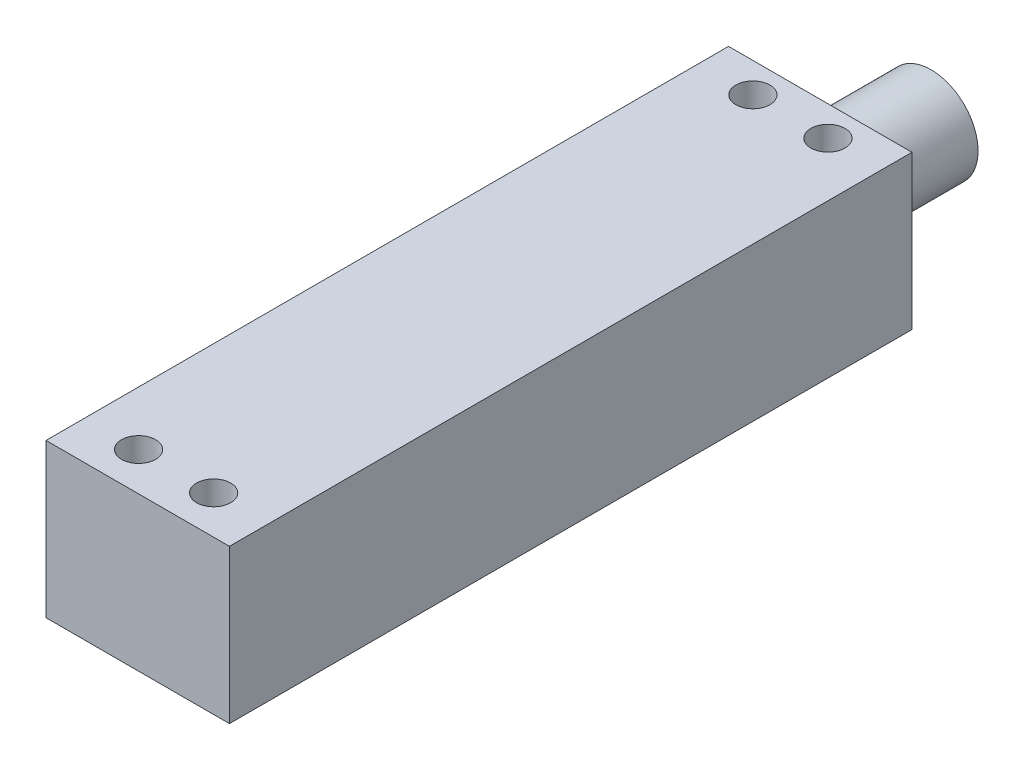
from build123d import *

# Parameters (mm, degrees)
BOSS_EXTRUDE6_START = 10
SKETCH22_W          = 21.5
SKETCH22_H          = 80
BOSS_EXTRUDE6_DEPTH = 18
SKETCH23_R          = 2
CUT_EXTRUDE9_DEPTH  = 4
SKETCH24_R          = 5.5
SKETCH24_R_2        = 4
BOSS_EXTRUDE7_DEPTH = 13


with BuildPart() as part:
    # Sketch22 → Boss-Extrude6 (new body)
    with BuildSketch(Plane(origin=(0, 0, 0), x_dir=(1, 0, 0), z_dir=(0, 1, 0)).offset(BOSS_EXTRUDE6_START)):
        with Locations((-5.25, -159.399454256)):
            Rectangle(SKETCH22_W, SKETCH22_H)
    extrude(amount=BOSS_EXTRUDE6_DEPTH)

    # Sketch23 → Cut-Extrude9 (cut)
    with BuildSketch(Plane(origin=(0, 28, 0), x_dir=(1, 0, 0), z_dir=(0, 1, 0))):
        with Locations((-9.65, -122.899454256)):
            Circle(SKETCH23_R)
        with Locations((-0.85, -122.899454256)):
            Circle(SKETCH23_R)
        with Locations((-0.85, -194.899454256)):
            Circle(SKETCH23_R)
        with Locations((-9.65, -194.899454256)):
            Circle(SKETCH23_R)
    extrude(amount=-CUT_EXTRUDE9_DEPTH, mode=Mode.SUBTRACT)

    # Sketch24 → Boss-Extrude7 (add)
    with BuildSketch(Plane(origin=(0, 0, 119.399454256), x_dir=(-1, 0, 0), z_dir=(0, 0, -1))):
        with Locations((5.25, 19)):
            Circle(SKETCH24_R)
        with Locations((5.25, 19)):
            Circle(SKETCH24_R_2, mode=Mode.SUBTRACT)
    extrude(amount=BOSS_EXTRUDE7_DEPTH)


solid = part.part
